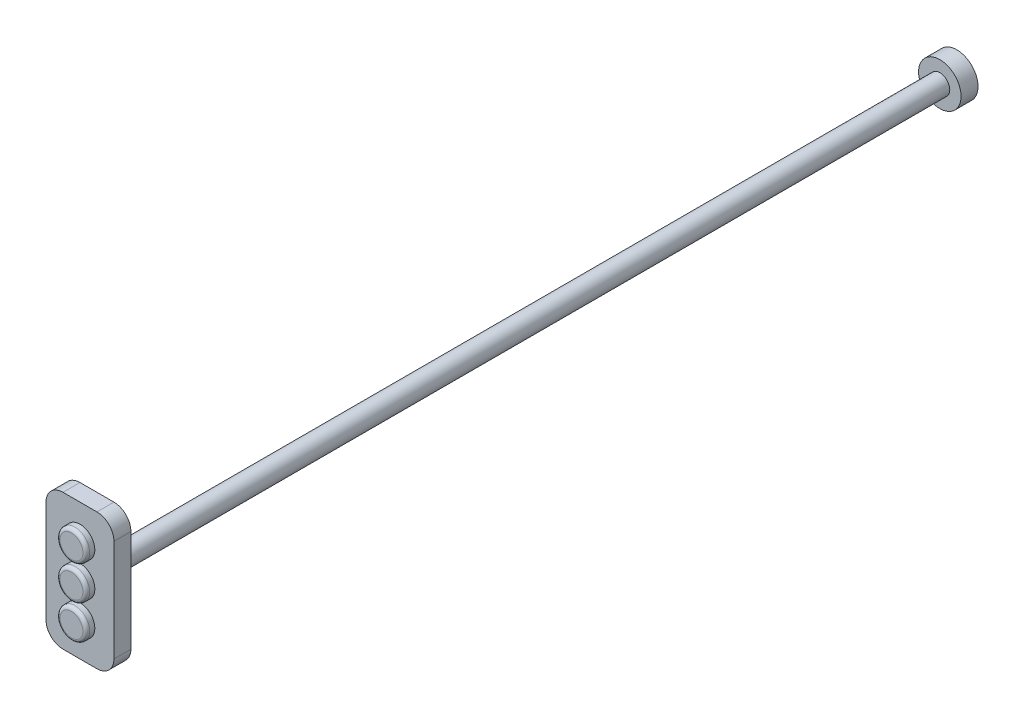
from build123d import *

# Parameters (mm, degrees)
SKETCH2_R                = 5.85
BOSS_EXTRUDE1_DEPTH      = 496
BOSS_EXTRUDE1_DEPTH_BACK = 0.3
SKETCH3_R                = 8.75
BOSS_EXTRUDE2_DEPTH      = 15
FILLET1_R                = 2
BOSS_EXTRUDE3_START      = -25
SKETCH5_R                = 8.75
BOSS_EXTRUDE3_DEPTH      = 15
BOSS_EXTRUDE3_2_DEPTH    = 15
FILLET2_R                = 2
FILLET3_R                = 2
BOSS_EXTRUDE4_START      = -25
BOSS_EXTRUDE4_DEPTH      = 10
SKETCH7_R                = 12.5
BOSS_EXTRUDE5_DEPTH      = 10


with BuildPart() as part:
    # Sketch2 → Boss-Extrude1 (new body, two sides)
    with BuildSketch(Plane.XY) as boss_extrude1_sk:
        Circle(SKETCH2_R)
    extrude(amount=BOSS_EXTRUDE1_DEPTH)
    extrude(boss_extrude1_sk.sketch, amount=-BOSS_EXTRUDE1_DEPTH_BACK)

    # Sketch3 → Boss-Extrude2 (add)
    with BuildSketch(Plane.XY.offset(496)):
        Circle(SKETCH3_R)
    extrude(amount=BOSS_EXTRUDE2_DEPTH)

    # Fillet1
    fillet1_edges = [part.edges().sort_by_distance(p)[0] for p in [
        (-8.75, 0, 511),
    ]]
    fillet(fillet1_edges, radius=FILLET1_R)



with BuildPart() as body_2:
    # Sketch5 → Boss-Extrude3 (new body)
    with BuildSketch(Plane.XY.offset(521).offset(BOSS_EXTRUDE3_START)):
        with Locations((0, 20)):
            Circle(SKETCH5_R)
    extrude(amount=BOSS_EXTRUDE3_DEPTH)

    # Fillet2
    fillet2_edges = [body_2.edges().sort_by_distance(p)[0] for p in [
        (-8.75, 20, 511),
    ]]
    fillet(fillet2_edges, radius=FILLET2_R)


with BuildPart() as body_3:
    # Sketch5 → Boss-Extrude3 2 (new body)
    with BuildSketch(Plane.XY.offset(521).offset(BOSS_EXTRUDE3_START)):
        with Locations((0, -20)):
            Circle(SKETCH5_R)
    extrude(amount=BOSS_EXTRUDE3_2_DEPTH)

    # Fillet3
    fillet3_edges = [body_3.edges().sort_by_distance(p)[0] for p in [
        (-8.75, -20, 511),
    ]]
    fillet(fillet3_edges, radius=FILLET3_R)


with BuildPart() as part_1:
    add(part.part)

    add(body_2.part)  # Boss-Extrude4 merges body 2

    add(body_3.part)  # Boss-Extrude4 merges body 3
    # Sketch6 → Boss-Extrude4 (add)
    with BuildSketch(Plane.XY.offset(521).offset(BOSS_EXTRUDE4_START)):
        with BuildLine():
            Line((10, -40), (-10, -40))
            ThreePointArc((-10, -40), (-17.071067812, -37.071067812), (-20, -30))
            Line((-20, -30), (-20, 30))
            ThreePointArc((-20, 30), (-17.071067812, 37.071067812), (-10, 40))
            Line((-10, 40), (10, 40))
            ThreePointArc((10, 40), (17.071067812, 37.071067812), (20, 30))
            Line((20, 30), (20, -30))
            ThreePointArc((20, -30), (17.071067812, -37.071067812), (10, -40))
        make_face()
    extrude(amount=BOSS_EXTRUDE4_DEPTH)

    # Sketch7 → Boss-Extrude5 (add)
    with BuildSketch(Plane(origin=(0, 0, -0.3), x_dir=(-1, 0, 0), z_dir=(0, 0, -1))):
        Circle(SKETCH7_R)
    extrude(amount=BOSS_EXTRUDE5_DEPTH)


solid = part_1.part
